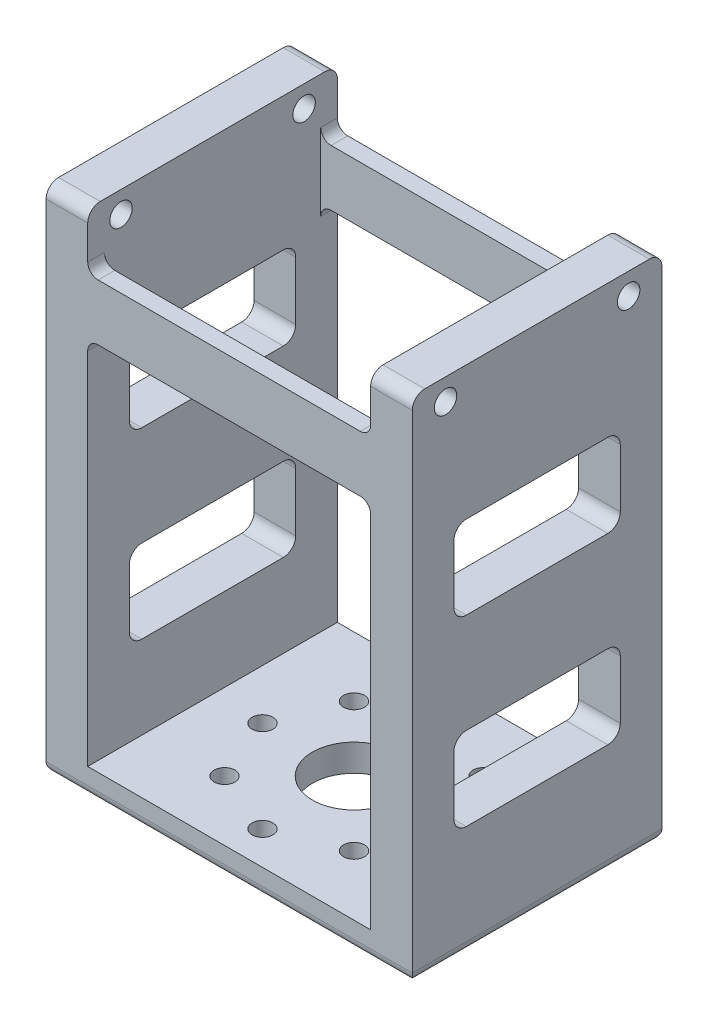
from build123d import *

# Parameters (mm, degrees)
SKETCH1_W            = 44
SKETCH1_H            = 30
BOSS_EXTRUDE1_DEPTH  = 54.5
SKETCH5_W            = 5
SKETCH5_H            = 30
BOSS_EXTRUDE3_DEPTH  = 6.8
SKETCH9_R            = 1.35
CUT_EXTRUDE6_DEPTH   = 79.604643629
FILLET1_R            = 1.5
FILLET2_R            = 1.25
SKETCH11_W           = 34
SKETCH11_H           = 26
CUT_EXTRUDE7_DEPTH   = 51.25
CUT_EXTRUDE8_REACH   = 83.202
SKETCH13_R           = 5
SKETCH13_R_2         = 1.25
CIRPATTERN1_COUNT    = 8
CUT_EXTRUDE10_REACH  = 83.202
SKETCH15_W           = 20
SKETCH15_H           = 10
FILLET6_R            = 1.5
FILLET6_OF_MIRROR4_R = 1.5
CUT_EXTRUDE11_REACH  = 83.202
SKETCH16_W           = 34
SKETCH16_H           = 44.5
FILLET7_R            = 1.25


with BuildPart() as part:
    # Sketch1 → Boss-Extrude1 (new body)
    with BuildSketch(Plane(origin=(0, 0, 0), x_dir=(1, 0, 0), z_dir=(0, 1, 0))):
        with Locations((22, 15)):
            Rectangle(SKETCH1_W, SKETCH1_H)
    extrude(amount=BOSS_EXTRUDE1_DEPTH)

    # Sketch5 → Boss-Extrude3 (add)
    with BuildSketch(Plane(origin=(0, 54.5, 0), x_dir=(1, 0, 0), z_dir=(0, 1, 0))):
        with Locations((2.5, 15)):
            Rectangle(SKETCH5_W, SKETCH5_H)
    boss_extrude3 = extrude(amount=BOSS_EXTRUDE3_DEPTH)

    # Sketch9 → Cut-Extrude6 (cut, through all)
    with BuildSketch(Plane(origin=(5, 0, 0), x_dir=(0, 0, -1), z_dir=(1, 0, 0))):
        with Locations((26, 58.7)):
            Circle(SKETCH9_R)
        with Locations((4, 58.7)):
            Circle(SKETCH9_R)
    cut_extrude6 = extrude(amount=-CUT_EXTRUDE6_DEPTH, mode=Mode.SUBTRACT)

    # Mirror2: Boss-Extrude3, Cut-Extrude6 across plane
    add(boss_extrude3.mirror(Plane.ZY.offset(-22)))
    add(cut_extrude6.mirror(Plane.ZY.offset(-22)), mode=Mode.SUBTRACT)

    # Fillet1
    fillet1_edges = [part.edges().sort_by_distance(p)[0] for p in [
        (41.5, 61.3, -30),
        (2.5, 61.3, -30),
        (2.5, 61.3, 0),
        (41.5, 61.3, 0),
    ]]
    fillet(fillet1_edges, radius=FILLET1_R)

    # Fillet2
    fillet2_edges = [part.edges().sort_by_distance(p)[0] for p in [
        (0, 0, -15),
        (22, 0, -30),
        (22, 0, 0),
        (44, 0, -15),
    ]]
    fillet(fillet2_edges, radius=FILLET2_R)

    # Sketch11 → Cut-Extrude7 (cut)
    with BuildSketch(Plane(origin=(0, 54.5, 0), x_dir=(1, 0, 0), z_dir=(0, 1, 0))):
        with Locations((22, 15)):
            Rectangle(SKETCH11_W, SKETCH11_H)
    extrude(amount=-CUT_EXTRUDE7_DEPTH, mode=Mode.SUBTRACT)

    # Sketch13 → Cut-Extrude8 (cut, up to next)
    with BuildSketch(Plane.XZ, mode=Mode.PRIVATE) as cut_extrude8_sk1:
        with Locations((22, -15)):
            Circle(SKETCH13_R)
    cut_extrude8_tool1 = extrude(cut_extrude8_sk1.sketch, amount=-CUT_EXTRUDE8_REACH, mode=Mode.PRIVATE) & part.part
    # Sketch13 → Cut-Extrude8 (cut, up to next)
    with BuildSketch(Plane.XZ, mode=Mode.PRIVATE) as cut_extrude8_sk2:
        with Locations((33, -15)):
            Circle(SKETCH13_R_2)
    cut_extrude8_tool2 = extrude(cut_extrude8_sk2.sketch, amount=-CUT_EXTRUDE8_REACH, mode=Mode.PRIVATE) & part.part
    cut_extrude8_1 = cut_extrude8_tool1.solids().sort_by_distance((22, 0, -15))[0]
    add(cut_extrude8_1, mode=Mode.SUBTRACT)
    cut_extrude8_2 = cut_extrude8_tool2.solids().sort_by_distance((33, 0, -15))[0]
    add(cut_extrude8_2, mode=Mode.SUBTRACT)
    cut_extrude8 = cut_extrude8_1 + cut_extrude8_2  # Cut-Extrude8 as one shape, for the pattern or mirror that repeats it

    # CirPattern1: Cut-Extrude8 ×8 about axis
    cirpattern1_axis = Axis((22, 0, -15), (0, -1, 0))
    for i in range(1, CIRPATTERN1_COUNT):
        add(cut_extrude8.rotate(cirpattern1_axis, i * 360 / CIRPATTERN1_COUNT), mode=Mode.SUBTRACT)

    # Sketch15 → Cut-Extrude10 (cut, up to next)
    with BuildSketch(Plane(origin=(44, 0, 0), x_dir=(0, 0, -1), z_dir=(1, 0, 0)), mode=Mode.PRIVATE) as cut_extrude10_sk1:
        with Locations((15, 18.25)):
            Rectangle(SKETCH15_W, SKETCH15_H)
    cut_extrude10_tool1 = extrude(cut_extrude10_sk1.sketch, amount=-CUT_EXTRUDE10_REACH, mode=Mode.PRIVATE) & part.part
    # Sketch15 → Cut-Extrude10 (cut, up to next)
    with BuildSketch(Plane(origin=(44, 0, 0), x_dir=(0, 0, -1), z_dir=(1, 0, 0)), mode=Mode.PRIVATE) as cut_extrude10_sk2:
        with Locations((15, 40.25)):
            Rectangle(SKETCH15_W, SKETCH15_H)
    cut_extrude10_tool2 = extrude(cut_extrude10_sk2.sketch, amount=-CUT_EXTRUDE10_REACH, mode=Mode.PRIVATE) & part.part
    cut_extrude10_1 = cut_extrude10_tool1.solids().sort_by_distance((44, 18.25, -15))[0]
    add(cut_extrude10_1, mode=Mode.SUBTRACT)
    cut_extrude10_2 = cut_extrude10_tool2.solids().sort_by_distance((44, 40.25, -15))[0]
    add(cut_extrude10_2, mode=Mode.SUBTRACT)
    cut_extrude10 = cut_extrude10_1 + cut_extrude10_2  # Cut-Extrude10 as one shape, for the pattern or mirror that repeats it

    # Fillet6
    fillet6_edges = [part.edges().sort_by_distance(p)[0] for p in [
        (41.5, 13.25, -5),
        (41.5, 35.25, -5),
        (41.5, 23.25, -5),
        (41.5, 45.25, -5),
        (41.5, 23.25, -25),
        (41.5, 45.25, -25),
        (41.5, 35.25, -25),
        (41.5, 13.25, -25),
    ]]
    fillet(fillet6_edges, radius=FILLET6_R)

    # Mirror4: Cut-Extrude10 across plane
    add(cut_extrude10.mirror(Plane.ZY.offset(-22)), mode=Mode.SUBTRACT)

    # Fillet6 of Mirror4
    fillet6_of_mirror4_edges = [part.edges().sort_by_distance(p)[0] for p in [
        (2.5, 13.25, -5),
        (2.5, 35.25, -5),
        (2.5, 23.25, -5),
        (2.5, 45.25, -5),
        (2.5, 23.25, -25),
        (2.5, 45.25, -25),
        (2.5, 35.25, -25),
        (2.5, 13.25, -25),
    ]]
    fillet(fillet6_of_mirror4_edges, radius=FILLET6_OF_MIRROR4_R)

    # Sketch16 → Cut-Extrude11 (cut, up to next)
    with BuildSketch(Plane.XY, mode=Mode.PRIVATE) as cut_extrude11_sk1:
        with Locations((22, 25.5)):
            Rectangle(SKETCH16_W, SKETCH16_H)
    cut_extrude11_tool1 = extrude(cut_extrude11_sk1.sketch, amount=-CUT_EXTRUDE11_REACH, mode=Mode.PRIVATE) & part.part
    cut_extrude11 = cut_extrude11_tool1.solids().sort_by_distance((22, 25.5, 0))[0]
    add(cut_extrude11, mode=Mode.SUBTRACT)

    # Mirror5: Cut-Extrude11 across plane
    add(cut_extrude11.mirror(Plane(origin=(0, 0, -15), x_dir=(1, 0, 0), z_dir=(0, 0, -1))), mode=Mode.SUBTRACT)

    # Fillet7
    fillet7_edges = [part.edges().sort_by_distance(p)[0] for p in [
        (5, 47.75, -29),
        (5, 47.75, -1),
        (5, 54.5, -1),
        (5, 54.5, -29),
        (39, 54.5, -1),
        (39, 54.5, -29),
        (39, 47.75, -29),
        (39, 47.75, -1),
    ]]
    fillet(fillet7_edges, radius=FILLET7_R)


solid = part.part
